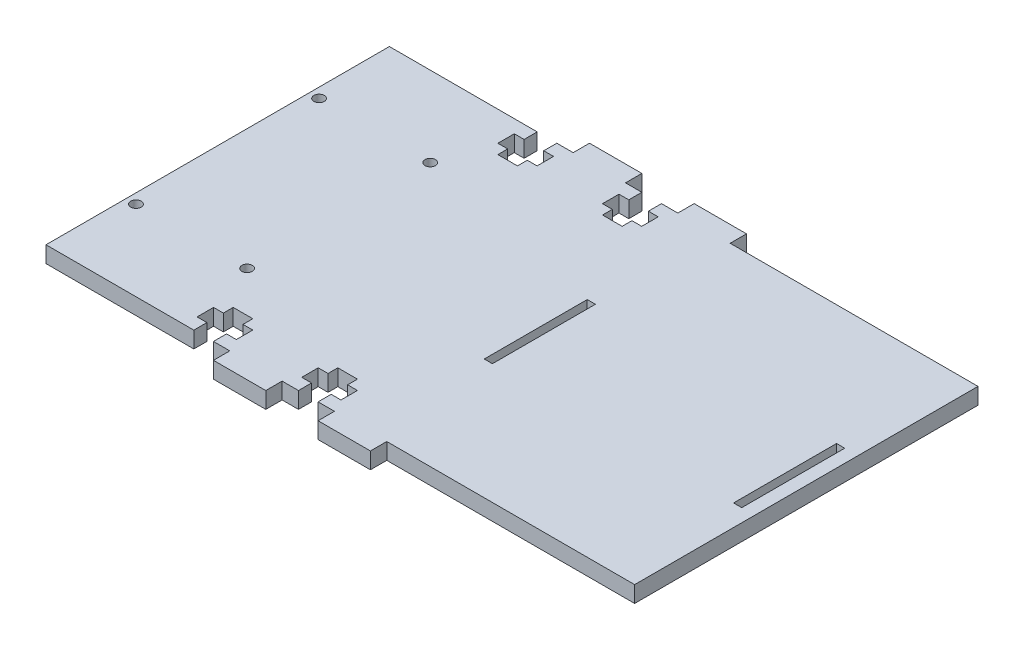
from build123d import *

# Parameters (mm, degrees)
SKETCH1_W           = 114.3
SKETCH1_H           = 66.675
SKETCH1_R           = 1.016
SKETCH1_W_2         = 1.5875
SKETCH1_H_2         = 20.0000108
BOSS_EXTRUDE1_DEPTH = 3.175
SKETCH2_W           = 10.16
SKETCH2_H           = 3.175
BOSS_EXTRUDE3_DEPTH = 3.175
CUT_EXTRUDE1_DEPTH  = 3.175


with BuildPart() as part:
    # Sketch1 → Boss-Extrude1 (new body)
    with BuildSketch(Plane(origin=(0, 0, 0), x_dir=(1, 0, 0), z_dir=(0, 1, 0))):
        with Locations((57.15, 33.3375)):
            Rectangle(SKETCH1_W, SKETCH1_H)
        with Locations((1.905, 15.5575)):
            Circle(SKETCH1_R, mode=Mode.SUBTRACT)
        with Locations((23.495, 15.5575)):
            Circle(SKETCH1_R, mode=Mode.SUBTRACT)
        with Locations((23.495, 51.1175)):
            Circle(SKETCH1_R, mode=Mode.SUBTRACT)
        with Locations((1.905, 51.1175)):
            Circle(SKETCH1_R, mode=Mode.SUBTRACT)
        with Locations((110.96625, 33.3375)):
            Rectangle(SKETCH1_W_2, SKETCH1_H_2, mode=Mode.SUBTRACT)
        with Locations((62.55385, 33.3375)):
            Rectangle(SKETCH1_W_2, SKETCH1_H_2, mode=Mode.SUBTRACT)
    extrude(amount=BOSS_EXTRUDE1_DEPTH)

    # Sketch2 → Boss-Extrude3 (add)
    with BuildSketch(Plane.XY):
        with Locations((40.770613131, 1.5875)):
            Rectangle(SKETCH2_W, SKETCH2_H)
        with Locations((61.090613131, 1.5875)):
            Rectangle(SKETCH2_W, SKETCH2_H)
    boss_extrude3 = extrude(amount=BOSS_EXTRUDE3_DEPTH)

    # Mirror2: Boss-Extrude3 across plane
    add(boss_extrude3.mirror(Plane(origin=(0, 3.175, -33.3375), x_dir=(1, 0, 0), z_dir=(0, 0, -1))))

    # Sketch4 → Cut-Extrude1 (cut)
    with BuildSketch(Plane(origin=(0, 3.175, 0), x_dir=(1, 0, 0), z_dir=(0, 1, 0))):
        Polygon((28.705613131, 0), (28.705613131, 2.54), (26.800613131, 2.54), (26.800613131, 5.73532), (28.705613131, 5.73532), (28.705613131, 7.64032), (32.515613131, 7.64032), (32.515613131, 5.73532), (34.420613131, 5.73532), (34.420613131, 2.54), (32.515613131, 2.54), (32.515613131, 0), align=None)
        Polygon((49.025613131, 0), (49.025613131, 2.54), (47.120613131, 2.54), (47.120613131, 5.73532), (49.025613131, 5.73532), (49.025613131, 7.64032), (52.835613131, 7.64032), (52.835613131, 5.73532), (54.740613131, 5.73532), (54.740613131, 2.54), (52.835613131, 2.54), (52.835613131, 0), align=None)
        Polygon((52.835613131, 66.675), (52.835613131, 64.135), (54.740613131, 64.135), (54.740613131, 60.93968), (52.835613131, 60.93968), (52.835613131, 59.03468), (49.025613131, 59.03468), (49.025613131, 60.93968), (47.120613131, 60.93968), (47.120613131, 64.135), (49.025613131, 64.135), (49.025613131, 66.675), align=None)
        Polygon((32.515613131, 66.675), (32.515613131, 64.135), (34.420613131, 64.135), (34.420613131, 60.93968), (32.515613131, 60.93968), (32.515613131, 59.03468), (28.705613131, 59.03468), (28.705613131, 60.93968), (26.800613131, 60.93968), (26.800613131, 64.135), (28.705613131, 64.135), (28.705613131, 66.675), align=None)
    extrude(amount=-CUT_EXTRUDE1_DEPTH, mode=Mode.SUBTRACT)


solid = part.part
